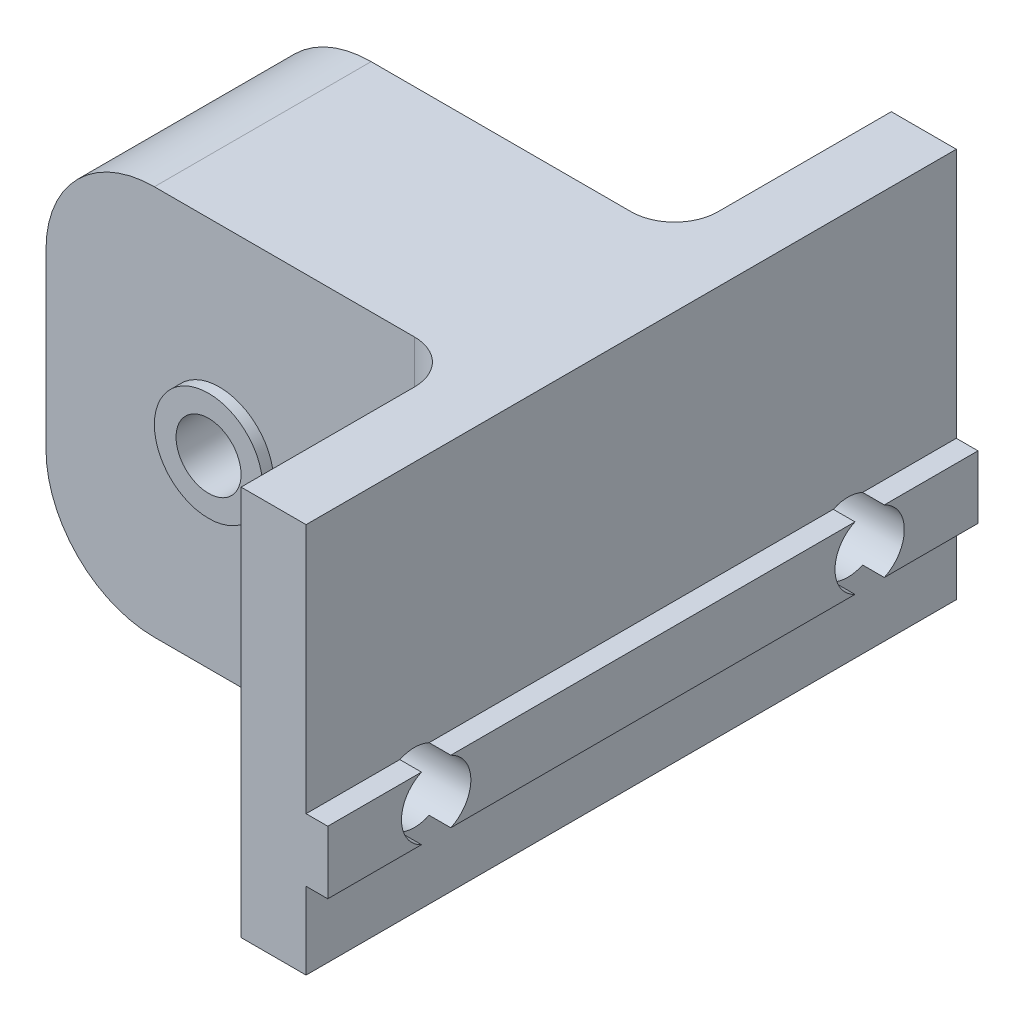
from build123d import *

# Parameters (mm, degrees)
MAIN_EXTRUSION_DEPTH            = 30
ESQUISSE2_W                     = 19
ESQUISSE2_H                     = 10
EXTERNAL_HOLE_DEPTH             = 37.986484018
ESQUISSE3_R                     = 1.6
MAKERBEAMFIXINGHOLE_DEPTH       = 38.815340802
ESQUISSE4_R                     = 1.5
HOLELINKWITHCODERSSUPPORT_DEPTH = 27.702059846
CONG_2_R                        = 2
CONG_3_R                        = 5
ESQUISSE6_R                     = 2.5
ESQUISSE6_R_2                   = 1.5
BOSS_EXTRU_1_DEPTH              = 0.5
ESQUISSE7_R                     = 2.5
ESQUISSE7_R_2                   = 1.5
BOSS_EXTRU_2_DEPTH              = 0.5


with BuildPart() as part:
    # Esquisse1 → Main Extrusion (new body)
    with BuildSketch(Plane.XY):
        Polygon((-11, 13), (-11, -5), (11, -5), (11, -1.45), (12, -1.45), (12, 1.45), (11, 1.45), (11, 13), align=None)
    extrude(amount=MAIN_EXTRUSION_DEPTH)

    # Esquisse2 → External Hole (cut, through all)
    with BuildSketch(Plane(origin=(0, 13, 0), x_dir=(1, 0, 0), z_dir=(0, 1, 0))):
        with Locations((-1.5, -5)):
            Rectangle(ESQUISSE2_W, ESQUISSE2_H)
        with Locations((-1.5, -25)):
            Rectangle(ESQUISSE2_W, ESQUISSE2_H)
    extrude(amount=-EXTERNAL_HOLE_DEPTH, mode=Mode.SUBTRACT)

    # Esquisse3 → MakerBeamFixingHole (cut, through all)
    with BuildSketch(Plane.ZY.offset(-8)):
        with Locations(Location((5, 0, 0), (0, 0, 270))):
            Circle(ESQUISSE3_R)
        with Locations(Location((25, 0, 0), (0, 0, 270))):
            Circle(ESQUISSE3_R)
    extrude(amount=-MAKERBEAMFIXINGHOLE_DEPTH, mode=Mode.SUBTRACT)

    # Esquisse4 → HoleLinkWithCodersSupport (cut, through all)
    with BuildSketch(Plane.XY.offset(20)):
        with Locations((-3, 4)):
            Circle(ESQUISSE4_R)
    extrude(amount=-HOLELINKWITHCODERSSUPPORT_DEPTH, mode=Mode.SUBTRACT)

    # Congé2
    cong_2_edges = [part.edges().sort_by_distance(p)[0] for p in [
        (8, 4, 10),
        (8, 4, 20),
    ]]
    fillet(cong_2_edges, radius=CONG_2_R)

    # Congé3
    cong_3_edges = [part.edges().sort_by_distance(p)[0] for p in [
        (-11, 13, 15),
        (-11, -5, 15),
    ]]
    fillet(cong_3_edges, radius=CONG_3_R)

    # Esquisse6 → Boss.-Extru.1 (add)
    with BuildSketch(Plane(origin=(0, 0, 10), x_dir=(-1, 0, 0), z_dir=(0, 0, -1))):
        with Locations(Location((3, 4, 0), (0, 0, 180))):
            Circle(ESQUISSE6_R)
        with Locations(Location((3, 4, 0), (0, 0, 180))):
            Circle(ESQUISSE6_R_2, mode=Mode.SUBTRACT)
    extrude(amount=BOSS_EXTRU_1_DEPTH)

    # Esquisse7 → Boss.-Extru.2 (add)
    with BuildSketch(Plane.XY.offset(20)):
        with Locations((-3, 4)):
            Circle(ESQUISSE7_R)
        with Locations((-3, 4)):
            Circle(ESQUISSE7_R_2, mode=Mode.SUBTRACT)
    extrude(amount=BOSS_EXTRU_2_DEPTH)


solid = part.part
